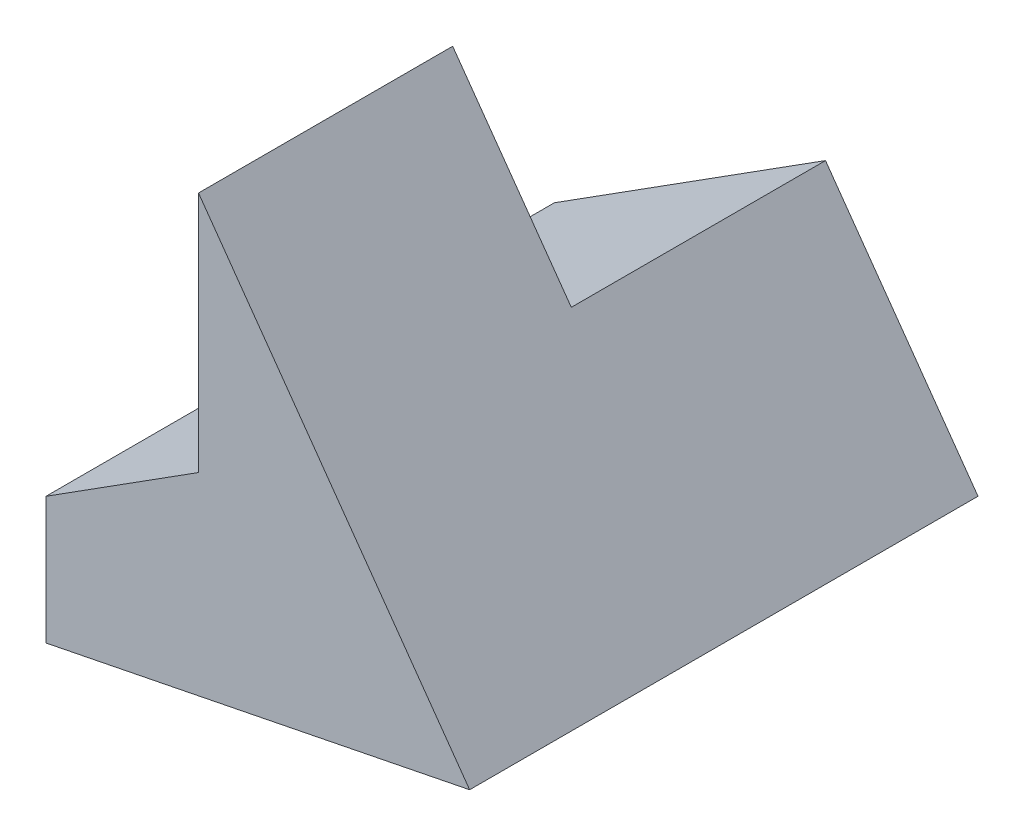
from build123d import *

# Parameters (mm, degrees)
BOSS_EXTRUDE1_DEPTH = 3
BOSS_EXTRUDE2_DEPTH = 3
BOSS_EXTRUDE3_DEPTH = 3
BOSS_EXTRUDE4_DEPTH = 3


with BuildPart() as part:
    # Sketch1 → Boss-Extrude1 (new body)
    with BuildSketch(Plane.XY):
        Polygon((0, 0), (5, 1), (1.8, 5.5), (1.8, 1.5), (0, 1.5), align=None)
    extrude(amount=BOSS_EXTRUDE1_DEPTH)

    # Sketch2 → Boss-Extrude2 (add)
    with BuildSketch(Plane(origin=(0, 0, 0), x_dir=(-1, 0, 0), z_dir=(0, 0, -1))):
        Polygon((-5, 1), (-3.2, 3.53125), (-3.2, 1.5), (0, 1.5), (0, 0), align=None)
    extrude(amount=BOSS_EXTRUDE2_DEPTH)

    # Sketch3 → Boss-Extrude3 (add)
    with BuildSketch(Plane(origin=(0, 0, -3), x_dir=(-1, 0, 0), z_dir=(0, 0, -1))):
        Polygon((-3.2, 3.53125), (0, 1.5), (-3.2, 1.5), align=None)
    extrude(amount=-BOSS_EXTRUDE3_DEPTH)

    # Sketch4 → Boss-Extrude4 (add)
    with BuildSketch(Plane.XY):
        Polygon((1.8, 2.642578125), (1.8, 1.5), (0, 1.5), align=None)
    extrude(amount=BOSS_EXTRUDE4_DEPTH)


solid = part.part
